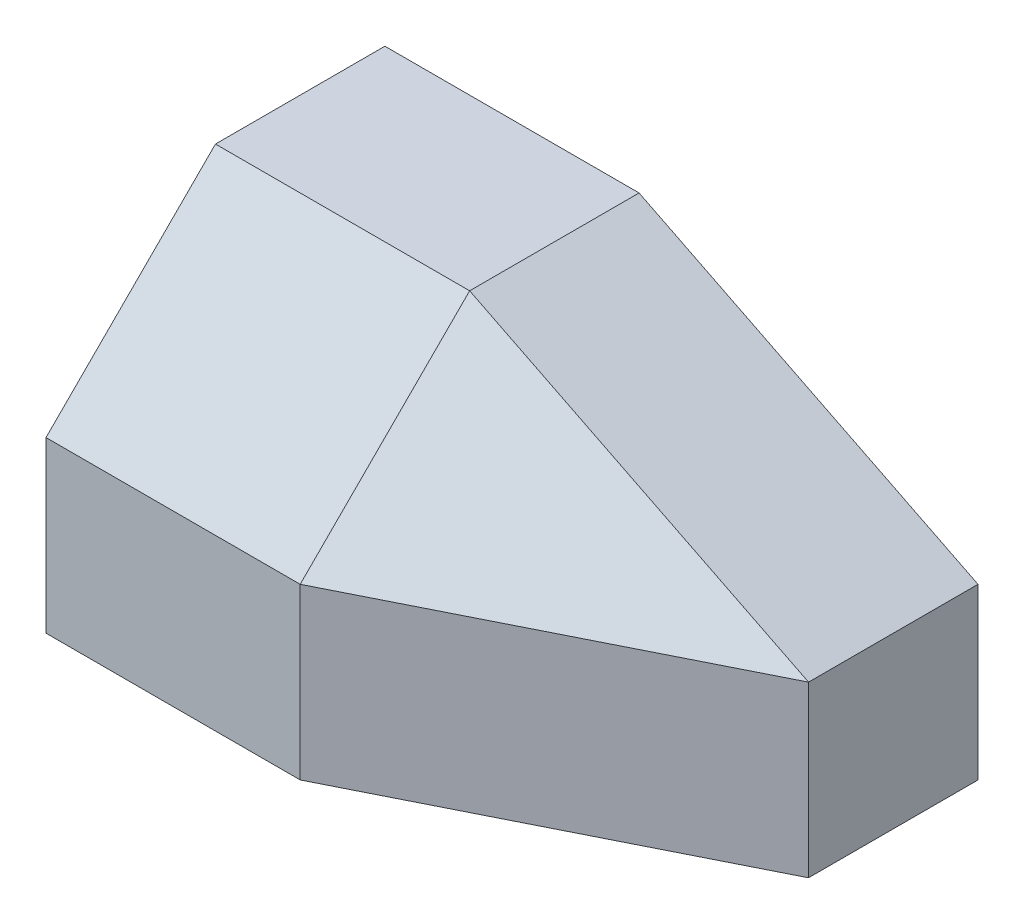
from build123d import *

# Parameters (mm, degrees)
BOSS_EXTRUDE1_DEPTH = 1016
CUT_EXTRUDE1_DEPTH  = 2287
CUT_EXTRUDE2_DEPTH  = 2287


with BuildPart() as part:
    # Sketch1 → Boss-Extrude1 (new body)
    with BuildSketch(Plane(origin=(0, 0, 0), x_dir=(1, 0, 0), z_dir=(0, 1, 0))):
        Polygon((0, 0), (0, 1016), (1778, 1016), (1778, 508), (762, 0), align=None)
    extrude(amount=BOSS_EXTRUDE1_DEPTH)

    # Sketch2 → Cut-Extrude1 (cut, through all)
    with BuildSketch(Plane(origin=(0, 0, -1016), x_dir=(-1, 0, 0), z_dir=(0, 0, -1))):
        Polygon((-762, 1016), (-1778, 508), (-1778, 1016), align=None)
    extrude(amount=-CUT_EXTRUDE1_DEPTH, mode=Mode.SUBTRACT)

    # Sketch3 → Cut-Extrude2 (cut, through all)
    with BuildSketch(Plane.ZY):
        Polygon((-508, 1016), (0, 508), (0, 1016), align=None)
    extrude(amount=-CUT_EXTRUDE2_DEPTH, mode=Mode.SUBTRACT)

    # SurfaceCut1
    split(bisect_by=Plane(origin=(197.555555556, 395.111111111, 395.111111111), x_dir=(-0.9428090415820636, 0.23570226039551598, 0.235702260395515), z_dir=(-0.33333333333333287, -0.6666666666666685, -0.6666666666666652)), keep=Keep.TOP)


solid = part.part
